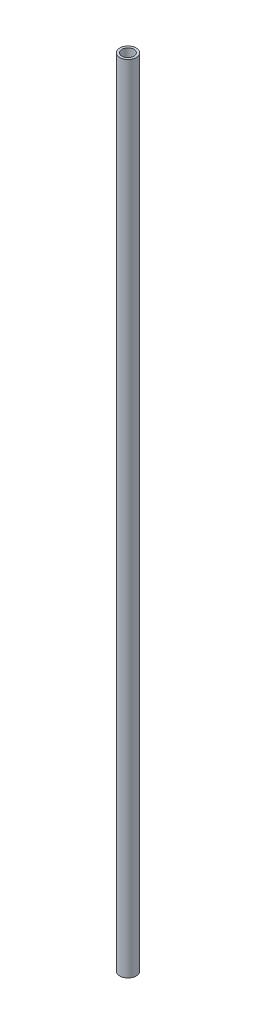
from build123d import *

# Parameters (mm, degrees)
SKETCH1_R           = 3.175
SKETCH1_R_2         = 2.286
BOSS_EXTRUDE1_DEPTH = 304.8


with BuildPart() as part:
    # Sketch1 → Boss-Extrude1 (new body)
    with BuildSketch(Plane(origin=(0, 0, 0), x_dir=(1, 0, 0), z_dir=(0, 1, 0))):
        Circle(SKETCH1_R)
        Circle(SKETCH1_R_2, mode=Mode.SUBTRACT)
    extrude(amount=BOSS_EXTRUDE1_DEPTH)


solid = part.part
